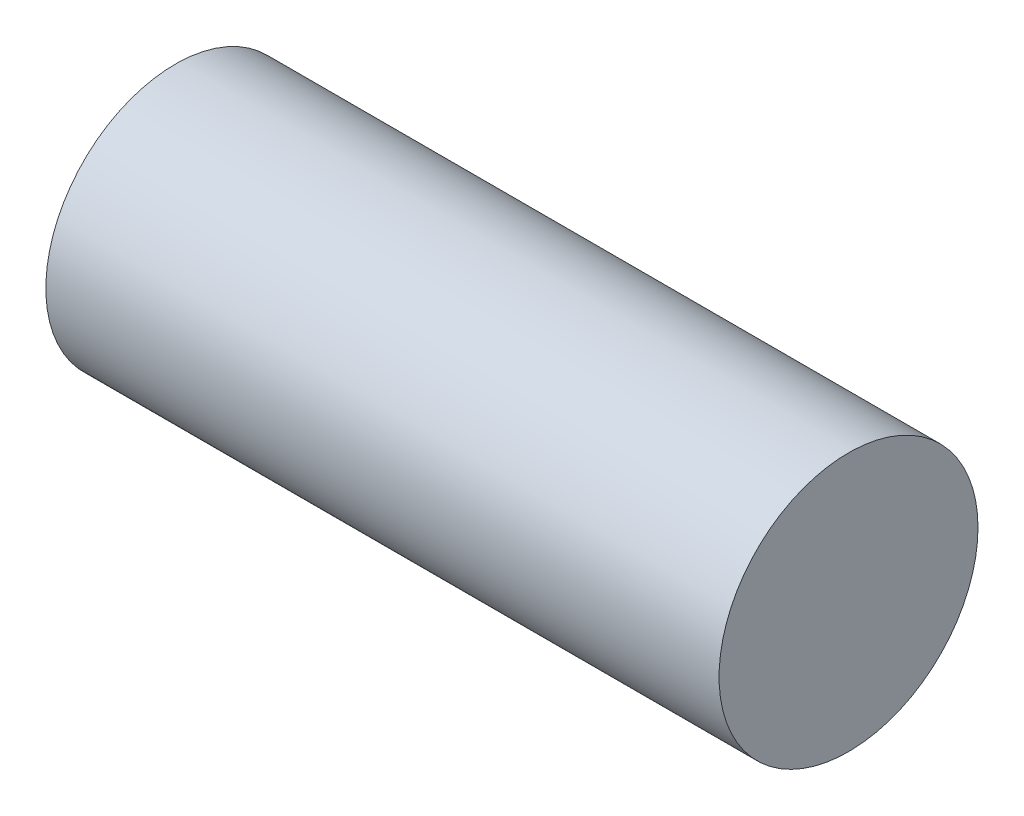
from build123d import *

# Parameters (mm, degrees)
SKETCH1_R      = 5
EXTRUDE1_DEPTH = 26


with BuildPart() as part:
    # Sketch1 → Extrude1 (new body)
    with BuildSketch(Plane(origin=(0, 0, 0), x_dir=(0, 0, -1), z_dir=(1, 0, 0))):
        Circle(SKETCH1_R)
    extrude(amount=EXTRUDE1_DEPTH)


solid = part.part
